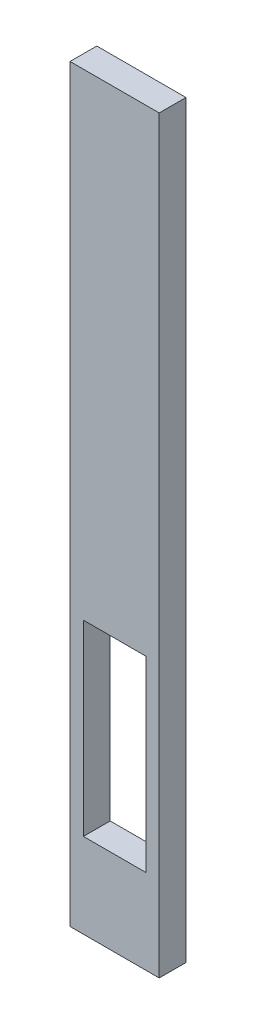
from build123d import *

# Parameters (mm, degrees)
ESBO_O1_W                = 10
ESBO_O1_H                = 9
ESBO_O1_H_2              = 66
ESBO_O1_W_2              = 7
ESBO_O1_H_3              = 21
RESSALTO_EXTRUS_O1_DEPTH = 3


with BuildPart() as part:
    # Esboço1 → Ressalto-extrusão1 (new body)
    with BuildSketch(Plane.XY):
        with Locations((-4.707063062, 47.072338936)):
            Rectangle(ESBO_O1_W, ESBO_O1_H)
        with Locations((-4.707063062, 9.572338936)):
            Rectangle(ESBO_O1_W, ESBO_O1_H_2)
        with Locations((-4.707063062, -12.427661064)):
            Rectangle(ESBO_O1_W_2, ESBO_O1_H_3, mode=Mode.SUBTRACT)
        with Locations((-4.707063062, -27.927661064)):
            Rectangle(ESBO_O1_W, ESBO_O1_H)
    extrude(amount=RESSALTO_EXTRUS_O1_DEPTH)


solid = part.part
